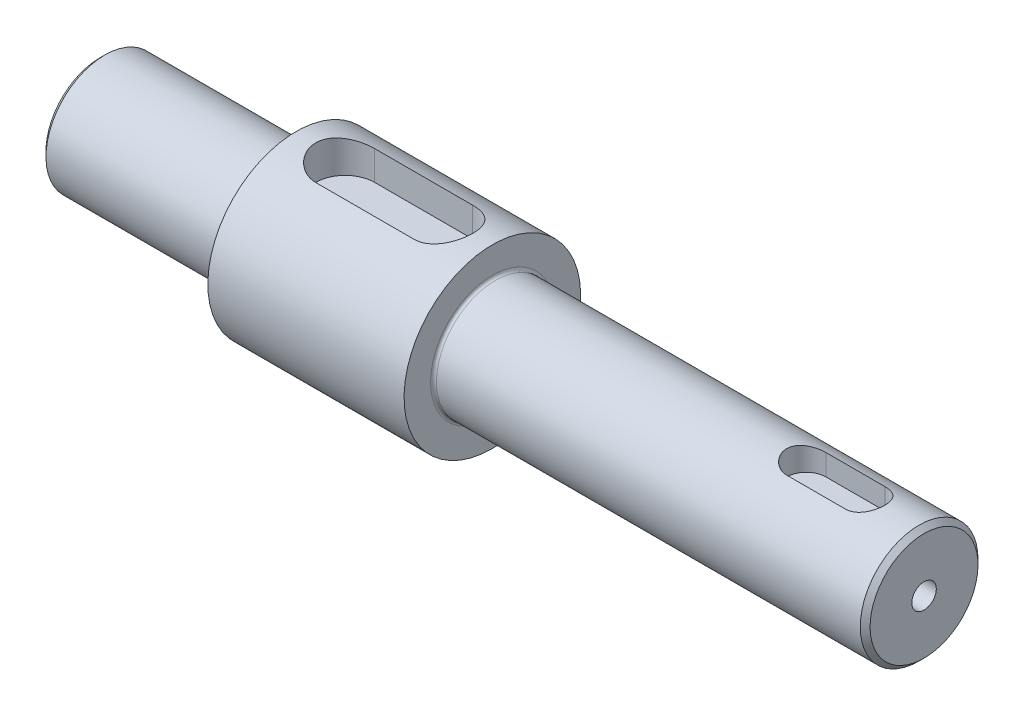
from build123d import *

# Parameters (mm, degrees)
CUT_EXTRUDE1_START    = 5.5
CUT_EXTRUDE1_DEPTH    = 10
SKETCH8_R             = 6
CUT_EXTRUDE4_DEPTH    = 6
CUT_EXTRUDE5_START    = 6
CUT_EXTRUDE5_DEPTH    = 2.5
FILLET1_R             = 0.3
CHAMFER1_SIZE         = 0.5
M3_TAPPED_HOLE1_D     = 2.5
M3_TAPPED_HOLE1_DEPTH = 6.748924226
M3_TAPPED_HOLE1_TIP   = 0.751075774


with BuildPart() as part:
    # Sketch3 → Revolve1 (revolve)
    with BuildSketch(Plane.XY):
        Polygon((-10, 9), (10, 9), (10, 6), (32, 6), (60, 6), (60, 0), (-30, 0), (-30, 6), (-10, 6), align=None)
    revolve(axis=Axis((-30, 0, 0), (1, 0, 0)))

    # Sketch5 → Cut-Extrude1 (cut)
    with BuildSketch(Plane(origin=(0, 0, 0), x_dir=(1, 0, 0), z_dir=(0, 1, 0)).offset(CUT_EXTRUDE1_START)):
        with BuildLine():
            Line((5, -3), (-5, -3))
            ThreePointArc((-5, -3), (-8, 0), (-5, 3))
            Line((-5, 3), (5, 3))
            ThreePointArc((5, 3), (8, 0), (5, -3))
        make_face()
    extrude(amount=CUT_EXTRUDE1_DEPTH, mode=Mode.SUBTRACT)

    # Sketch8 → Cut-Extrude4 (cut)
    with BuildSketch(Plane(origin=(60, 0, 0), x_dir=(0, 0, -1), z_dir=(1, 0, 0))):
        Circle(SKETCH8_R)
    extrude(amount=-CUT_EXTRUDE4_DEPTH, mode=Mode.SUBTRACT)

    # Sketch9 → Cut-Extrude5 (cut)
    with BuildSketch(Plane(origin=(0, 0, 0), x_dir=(1, 0, 0), z_dir=(0, 1, 0)).offset(CUT_EXTRUDE5_START)):
        with BuildLine():
            Line((42, 2), (48, 2))
            ThreePointArc((48, 2), (50, 0), (48, -2))
            Line((48, -2), (42, -2))
            ThreePointArc((42, -2), (40, 0), (42, 2))
        make_face()
    extrude(amount=-CUT_EXTRUDE5_DEPTH, mode=Mode.SUBTRACT)

    # Fillet1
    fillet1_edges = [part.edges().sort_by_distance(p)[0] for p in [
        (-10, -6, 0),
        (10, -6, 0),
    ]]
    fillet(fillet1_edges, radius=FILLET1_R)

    # Chamfer1
    chamfer1_edges = [part.edges().sort_by_distance(p)[0] for p in [
        (-30, -6, 0),
        (54, -6, 0),
    ]]
    chamfer(chamfer1_edges, length=CHAMFER1_SIZE)

    # M3 Tapped Hole1
    with Locations(Plane(origin=(54, 0, 0), x_dir=(0, 0, -1), z_dir=(1, 0, 0))):
        with Locations((0, 0)):
            Hole(M3_TAPPED_HOLE1_D / 2, depth=M3_TAPPED_HOLE1_DEPTH)
            with Locations((0, 0, -(M3_TAPPED_HOLE1_DEPTH + M3_TAPPED_HOLE1_TIP / 2))):  # 118° drill point
                Cone(0, M3_TAPPED_HOLE1_D / 2, M3_TAPPED_HOLE1_TIP, mode=Mode.SUBTRACT)


solid = part.part
